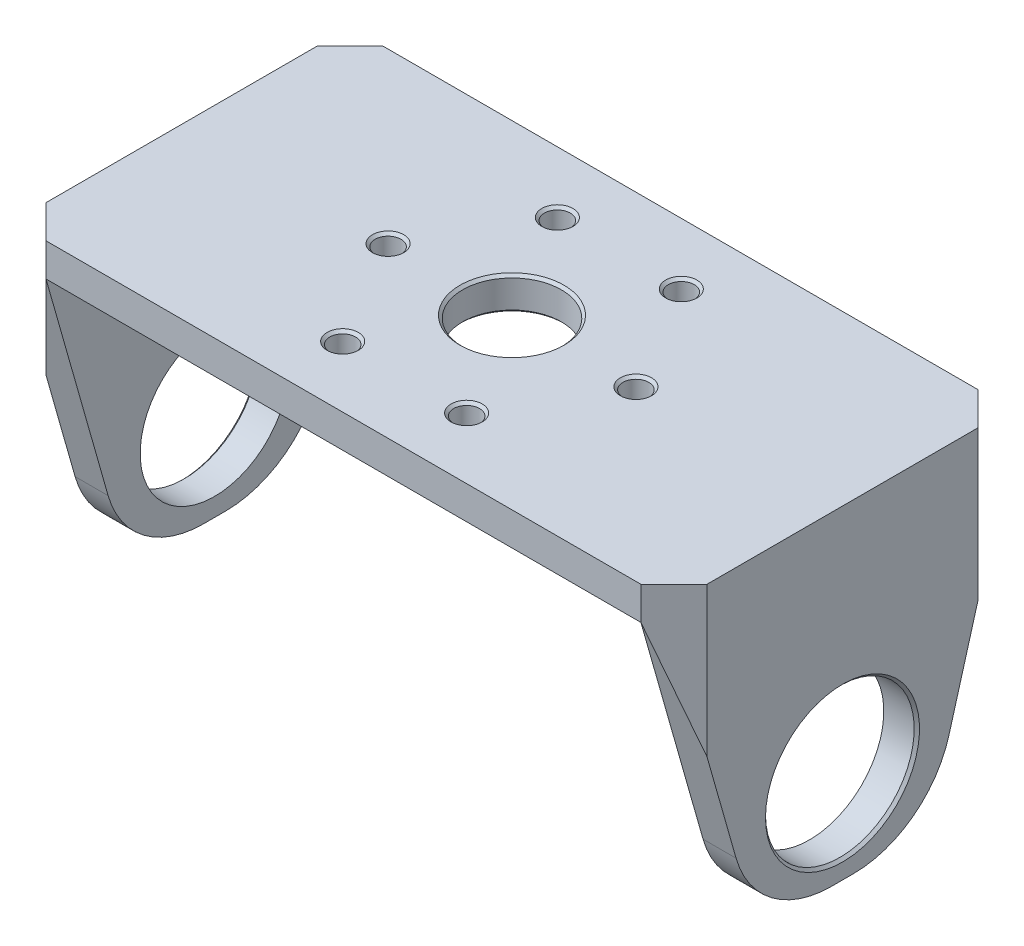
from build123d import *

# Parameters (mm, degrees)
SKETCH1_W                      = 114.3
SKETCH1_H                      = 64.77
BOSS_EXTRUDE1_DEPTH            = 6.35
BOSS_EXTRUDE2_DEPTH            = 6.35
BOSS_EXTRUDE3_DEPTH            = 6.35
HOLE1_D                        = 18.9738
HOLE1_DEPTH                    = 6.35
F_9_0_196_DIAMETER_HOLE1_D     = 4.9784
F_9_0_196_DIAMETER_HOLE1_DEPTH = 62.23
F_9_0_196_DIAMETER_HOLE2_D     = 4.9784
F_9_0_196_DIAMETER_HOLE2_DEPTH = 6.35
HOLE2_D                        = 28.575
HOLE2_DEPTH                    = 6.35
HOLE3_D                        = 28.575
HOLE3_DEPTH                    = 127
CHAMFER1_SIZE                  = 6.35
CHAMFER2_SIZE                  = 0.508
FILLET1_R                      = 19.05


with BuildPart() as part:
    # Sketch1 → Boss-Extrude1 (new body)
    with BuildSketch(Plane(origin=(0, 6.35, 0), x_dir=(1, 0, 0), z_dir=(0, 1, 0))):
        Rectangle(SKETCH1_W, SKETCH1_H)
    extrude(amount=-BOSS_EXTRUDE1_DEPTH)

    # Sketch2 → Boss-Extrude2 (add)
    with BuildSketch(Plane(origin=(57.15, 0, 0), x_dir=(0, 0, -1), z_dir=(1, 0, 0))):
        Polygon((-32.385, 6.35), (32.385, 6.35), (32.385, 0), (16.51, -55.88), (-16.51, -55.88), (-32.385, 0), align=None)
    extrude(amount=BOSS_EXTRUDE2_DEPTH)

    # Sketch3 → Boss-Extrude3 (add)
    with BuildSketch(Plane.ZY.offset(57.15)):
        Polygon((32.385, 0), (16.51, -55.88), (-16.51, -55.88), (-32.385, 0), (-32.385, 6.35), (32.385, 6.35), align=None)
    extrude(amount=BOSS_EXTRUDE3_DEPTH)

    # Hole1
    with Locations(Plane(origin=(0, 0, 0), x_dir=(-1, 0, 0), z_dir=(0, -1, 0))):
        with Locations((0, 0)):
            Hole(HOLE1_D / 2, depth=HOLE1_DEPTH)

    # #9 (0.196) Diameter Hole1
    with Locations(Plane(origin=(0, 6.35, 0), x_dir=(1, 0, 0), z_dir=(0, 1, 0))):
        with Locations((11.90625, 20.622229928)):
            Hole(F_9_0_196_DIAMETER_HOLE1_D / 2, depth=F_9_0_196_DIAMETER_HOLE1_DEPTH)

    # #9 (0.196) Diameter Hole2
    with Locations(Plane(origin=(0, 0, 0), x_dir=(-1, 0, 0), z_dir=(0, -1, 0))):
        with Locations((-23.8125, 0), (-11.90625, -20.622229928), (11.90625, -20.622229928), (23.8125, 0), (11.90625, 20.622229928)):
            Hole(F_9_0_196_DIAMETER_HOLE2_D / 2, depth=F_9_0_196_DIAMETER_HOLE2_DEPTH)

    # Hole2
    with Locations(Plane.ZY.offset(63.5)):
        with Locations((0, -38.1)):
            Hole(HOLE2_D / 2, depth=HOLE2_DEPTH)

    # Hole3
    with Locations(Plane(origin=(63.5, 0, 0), x_dir=(0, 0, -1), z_dir=(1, 0, 0))):
        with Locations((0, -38.1)):
            Hole(HOLE3_D / 2, depth=HOLE3_DEPTH)

    # Chamfer1
    chamfer1_edges = [part.edges().sort_by_distance(p)[0] for p in [
        (63.5, 3.175, -32.385),
        (63.5, 3.175, 32.385),
        (-63.5, 3.175, -32.385),
        (-63.5, 3.175, 32.385),
    ]]
    chamfer(chamfer1_edges, length=CHAMFER1_SIZE)

    # Chamfer2
    chamfer2_edges = [part.edges().sort_by_distance(p)[0] for p in [
        (-9.4869, 0, 0),
        (-9.4869, 6.35, 0),
        (14.39545, 0, -20.622229928),
        (14.39545, 6.35, -20.622229928),
        (-14.39545, 0, -20.622229928),
        (-14.39545, 6.35, -20.622229928),
        (-26.3017, 0, 0),
        (-26.3017, 6.35, 0),
        (-14.39545, 0, 20.622229928),
        (-14.39545, 6.35, 20.622229928),
        (9.41705, 0, 20.622229928),
        (9.41705, 6.35, 20.622229928),
        (21.3233, 0, 0),
        (21.3233, 6.35, 0),
        (-63.5, -38.1, 14.2875),
        (63.5, -38.1, -14.2875),
    ]]
    chamfer(chamfer2_edges, length=CHAMFER2_SIZE)

    # Fillet1
    fillet1_edges = [part.edges().sort_by_distance(p)[0] for p in [
        (60.325, -55.88, 16.51),
        (60.325, -55.88, -16.51),
        (-60.325, -55.88, -16.51),
        (-60.325, -55.88, 16.51),
    ]]
    fillet(fillet1_edges, radius=FILLET1_R)


solid = part.part
